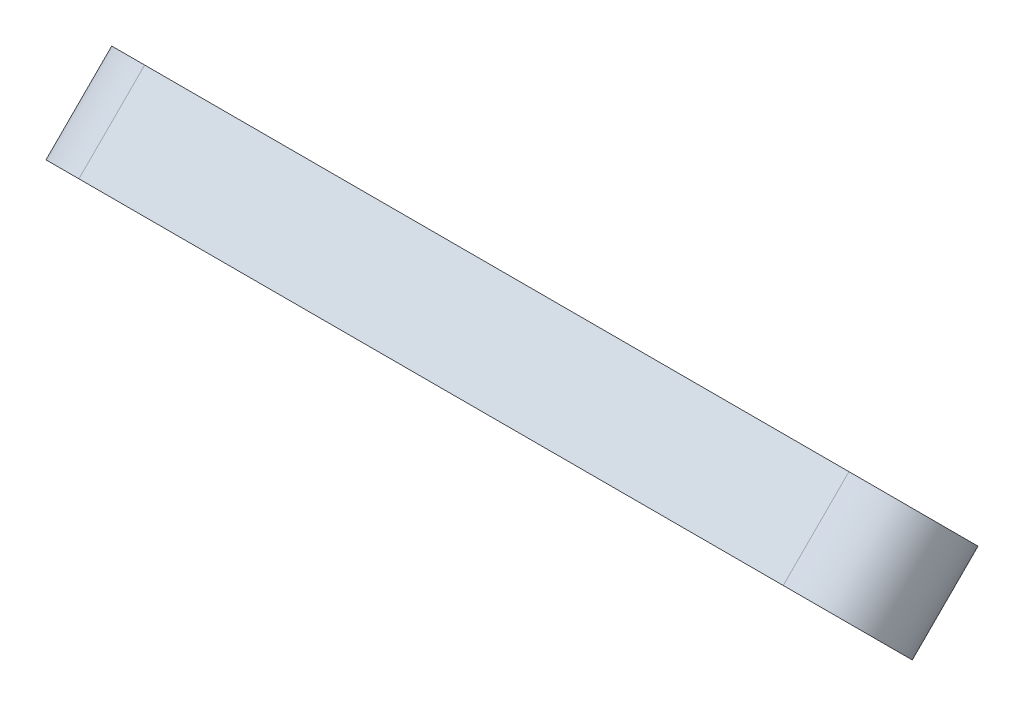
from build123d import *

# Parameters (mm, degrees)
SKETCH1_R           = 2.3114
SKETCH1_R_2         = 2.286
BOSS_EXTRUDE1_DEPTH = 12.7


with BuildPart() as part:
    # Sketch1 → Boss-Extrude1 (new body)
    with BuildSketch(Plane(origin=(0, 37.922464563, -37.922464563), x_dir=(-1, 0, 0), z_dir=(0, 0.707106781, -0.707106781))):
        with BuildLine():
            Line((-134.207627879, 519.168586126), (-36.620827879, 517.26819603))
            ThreePointArc((-36.620827879, 517.26819603), (-27.759939628, 508.055342556), (-36.972793102, 499.194454305))
            Line((-36.972793102, 499.194454305), (-134.559593102, 501.094844401))
            ThreePointArc((-134.559593102, 501.094844401), (-143.420481353, 510.307697875), (-134.207627879, 519.168586126))
        make_face()
        with Locations((-134.383610491, 510.131715264)):
            Circle(SKETCH1_R, mode=Mode.SUBTRACT)
        with Locations((-36.796810491, 508.231325167)):
            Circle(SKETCH1_R, mode=Mode.SUBTRACT)
        with Locations((-60.190210491, 508.686884584)):
            Circle(SKETCH1_R_2, mode=Mode.SUBTRACT)
        with Locations((-110.990210491, 509.676155847)):
            Circle(SKETCH1_R_2, mode=Mode.SUBTRACT)
    extrude(amount=BOSS_EXTRUDE1_DEPTH)


solid = part.part
